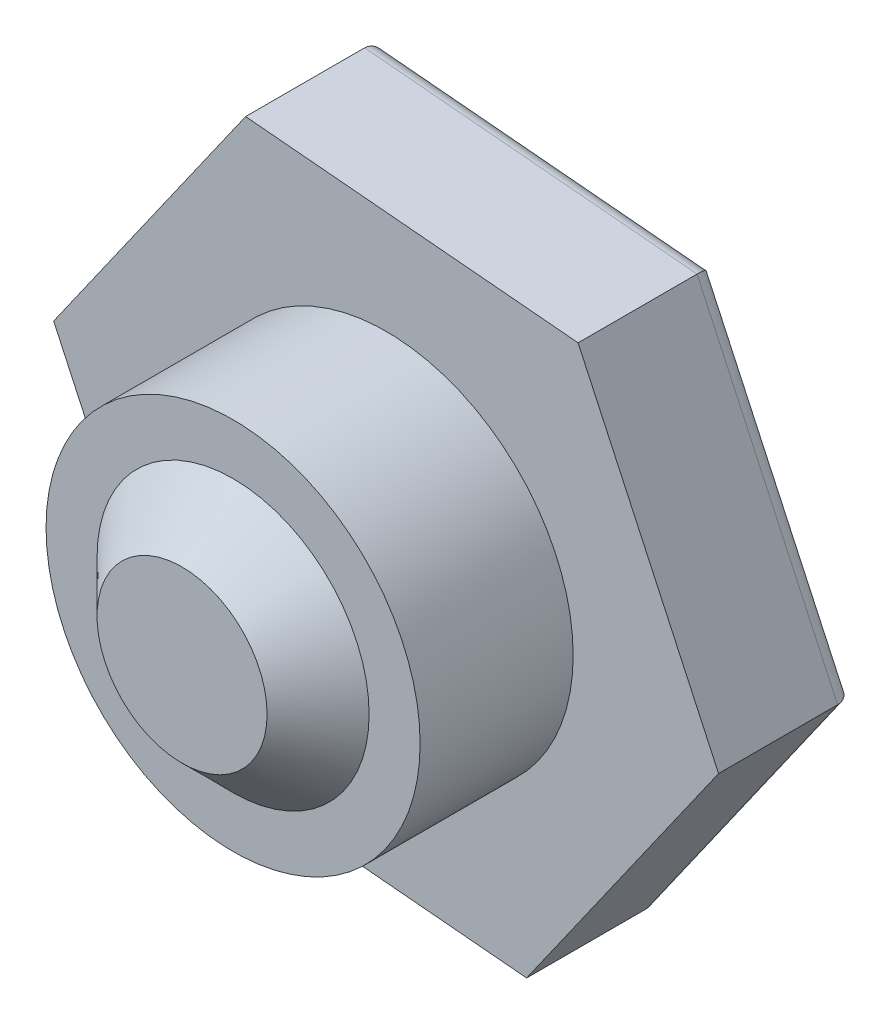
from build123d import *

# Parameters (mm, degrees)
SCHIZZO1_R                   = 11
ESTRUSIONE_ESTRUSIONE1_DEPTH = 9
ESTRUSIONE_ESTRUSIONE2_DEPTH = 8
RACCORDO1_R                  = 1
SCHIZZO5_R                   = 8
SCHIZZO4_R                   = 5


with BuildPart() as part:
    # Schizzo1 → Estrusione-Estrusione1 (new body)
    with BuildSketch(Plane.XY):
        Circle(SCHIZZO1_R)
    extrude(amount=ESTRUSIONE_ESTRUSIONE1_DEPTH)

    # Schizzo2 → Estrusione-Estrusione2 (add)
    with BuildSketch(Plane(origin=(0, 0, 0), x_dir=(-1, 0, 0), z_dir=(0, 0, -1))):
        Polygon((-19.551988484, -1.747306402), (-8.26278251, -17.806171922), (11.289205974, -16.058865521), (19.551988484, 1.747306402), (8.26278251, 17.806171922), (-11.289205974, 16.058865521), align=None)
    extrude(amount=ESTRUSIONE_ESTRUSIONE2_DEPTH)

    # Raccordo1
    raccordo1_edges = [part.edges().sort_by_distance(p)[0] for p in [
        (1.513211732, 16.932518721, -8),
        (15.420597229, 7.155779559, -8),
        (13.907385497, -9.776739162, -8),
        (-1.513211732, -16.932518721, -8),
        (-15.420597229, -7.155779559, -8),
        (-13.907385497, 9.776739162, -8),
    ]]
    fillet(raccordo1_edges, radius=RACCORDO1_R)

    # Schizzo5 → Loft1 section 0
    with BuildSketch(Plane.XY.offset(9)):
        Circle(SCHIZZO5_R)
    # Schizzo4 → Loft1 section 1
    with BuildSketch(Plane.XY.offset(12)):
        Circle(SCHIZZO4_R)
    loft()


solid = part.part
